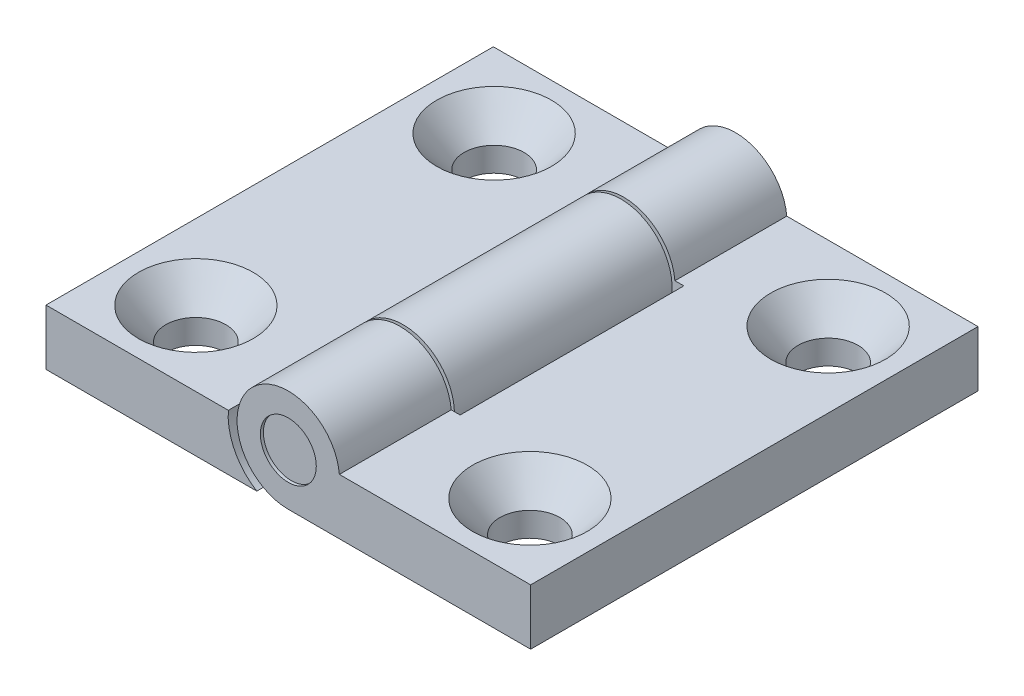
from build123d import *

# Parameters (mm, degrees)
SKETCH1_R                                    = 2.38125
EXTRUDE1_DEPTH                               = 19.05
CUT_EXTRUDE1_DEPTH                           = 9.525
CUT_EXTRUDE2_DEPTH                           = 9.525
SKETCH4_W                                    = 10.221376894
SKETCH4_H                                    = 0.254
CUT_EXTRUDE4_DEPTH                           = 9.73125
SKETCH5_R                                    = 2.38125
EXTRUDE2_DEPTH                               = 18.796
CSK_FOR_10_FLAT_HEAD_MACHINE_SCREW1_AT_COUNT = 2
CSK_FOR_10_FLAT_HEAD_MACHINE_SCREW1_AT_PITCH = 25.4
CSK_FOR_10_FLAT_HEAD_MACHINE_SCREW1_2_COUNT  = 2
CSK_FOR_10_FLAT_HEAD_MACHINE_SCREW1_2_PITCH  = 38.137235138
CSK_FOR_10_FLAT_HEAD_MACHINE_SCREW1_3_COUNT  = 2
CSK_FOR_10_FLAT_HEAD_MACHINE_SCREW1_3_PITCH  = 28.448


with BuildPart() as part:
    # Sketch1 → Extrude1 (new body, symmetric)
    with BuildSketch(Plane.XY):
        with BuildLine():
            Line((4.348688447, 4.7498), (20.6375, 4.7498))
            Line((20.6375, 4.7498), (20.6375, 0))
            Line((20.6375, 0), (-20.6375, 0))
            Line((-20.6375, 0), (-20.6375, 4.7498))
            Line((-20.6375, 4.7498), (-4.348688447, 4.7498))
            ThreePointArc((-4.348688447, 4.7498), (0, 8.73125), (4.348688447, 4.7498))
        make_face()
        with Locations((0, 4.365625)):
            Circle(SKETCH1_R, mode=Mode.SUBTRACT)
    extrude(amount=EXTRUDE1_DEPTH, both=True)

    # Sketch2 → Cut-Extrude1 (cut)
    with BuildSketch(Plane.XY.offset(19.05)):
        with BuildLine():
            Line((-5.110688447, 4.7498), (-4.348688447, 4.7498))
            ThreePointArc((-4.348688447, 4.7498), (-3.219925902, 1.417615701), (0, 0))
            Line((0, 0), (-2.684780288, 0))
            ThreePointArc((-2.684780288, 0), (-4.564261518, 2.034478581), (-5.110688447, 4.7498))
        make_face()
    cut_extrude1 = extrude(amount=-CUT_EXTRUDE1_DEPTH, mode=Mode.SUBTRACT)

    # Mirror1: Cut-Extrude1 across plane
    add(cut_extrude1.mirror(Plane.XY), mode=Mode.SUBTRACT)

    # Sketch3 → Cut-Extrude2 (cut, symmetric)
    with BuildSketch(Plane.XY):
        with BuildLine():
            Line((4.348688447, 4.7498), (5.110688447, 4.7498))
            ThreePointArc((5.110688447, 4.7498), (4.564261518, 2.034478581), (2.684780288, 0))
            Line((2.684780288, 0), (0, 0))
            ThreePointArc((0, 0), (3.219925902, 1.417615701), (4.348688447, 4.7498))
        make_face()
    extrude(amount=CUT_EXTRUDE2_DEPTH, both=True, mode=Mode.SUBTRACT)

    # Sketch4 → Cut-Extrude4 (cut, through all)
    with BuildSketch(Plane(origin=(0, 0, 0), x_dir=(1, 0, 0), z_dir=(0, 1, 0))):
        with Locations((0, 9.398)):
            Rectangle(SKETCH4_W, SKETCH4_H)
        with Locations((0, -9.398)):
            Rectangle(SKETCH4_W, SKETCH4_H)
    extrude(amount=CUT_EXTRUDE4_DEPTH, mode=Mode.SUBTRACT)

    # Sketch6 → CSK for #10 Flat Head Machine Screw1 (revolve, cut)
    with BuildSketch(Plane(origin=(-14.224, 4.7498, -12.7), x_dir=(0, 0, 1), z_dir=(1, 0, 0))):
        Polygon((0, 0), (0, 4.7498), (2.5527, 4.7498), (2.5527, 2.688180894), (4.8895, 0), align=None)
    csk_for_10_flat_head_machine_screw1 = revolve(axis=Axis((-14.224, 11.0998, -12.7), (0, -1, 0)), mode=Mode.SUBTRACT)

    # CSK for #10 Flat Head Machine Screw1 at: CSK for #10 Flat Head Machine Screw1 ×2
    with Locations(*[(0, 0, i * CSK_FOR_10_FLAT_HEAD_MACHINE_SCREW1_AT_PITCH) for i in range(1, CSK_FOR_10_FLAT_HEAD_MACHINE_SCREW1_AT_COUNT)]):
        add(csk_for_10_flat_head_machine_screw1, mode=Mode.SUBTRACT)

    # CSK for _10 Flat Head Machine Screw1 2: CSK for #10 Flat Head Machine Screw1 ×2
    with Locations(*[Vector(0.745937662, 0, 0.666015769) * (i * CSK_FOR_10_FLAT_HEAD_MACHINE_SCREW1_2_PITCH) for i in range(1, CSK_FOR_10_FLAT_HEAD_MACHINE_SCREW1_2_COUNT)]):
        add(csk_for_10_flat_head_machine_screw1, mode=Mode.SUBTRACT)

    # CSK for _10 Flat Head Machine Screw1 3: CSK for #10 Flat Head Machine Screw1 ×2
    with Locations(*[(i * CSK_FOR_10_FLAT_HEAD_MACHINE_SCREW1_3_PITCH, 0, 0) for i in range(1, CSK_FOR_10_FLAT_HEAD_MACHINE_SCREW1_3_COUNT)]):
        add(csk_for_10_flat_head_machine_screw1, mode=Mode.SUBTRACT)


with BuildPart() as body_2:
    # Sketch5 → Extrude2 (new body, symmetric)
    with BuildSketch(Plane.XY):
        with Locations((0, 4.365625)):
            Circle(SKETCH5_R)
    extrude(amount=EXTRUDE2_DEPTH, both=True)


solid = Compound([part.part, body_2.part])
